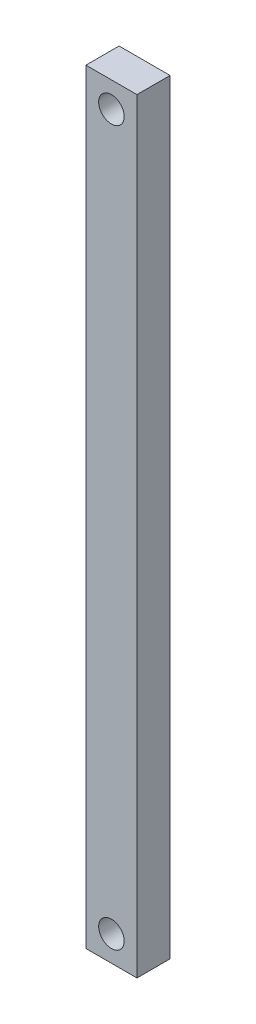
from build123d import *

# Parameters (mm, degrees)
SKETCH_1_W      = 10
SKETCH_1_H      = 150
SKETCH_1_R      = 2.5
EXTRUDE_1_DEPTH = 6.5


with BuildPart() as part:
    # 草图1 → 凸台-拉伸1 (new body)
    with BuildSketch(Plane.XY):
        with Locations((-8.886046419, -47.06351943)):
            Rectangle(SKETCH_1_W, SKETCH_1_H)
        with Locations((-8.886046419, 22.93648057)):
            Circle(SKETCH_1_R, mode=Mode.SUBTRACT)
        with Locations((-8.886046419, -117.06351943)):
            Circle(SKETCH_1_R, mode=Mode.SUBTRACT)
    extrude(amount=EXTRUDE_1_DEPTH)


solid = part.part
